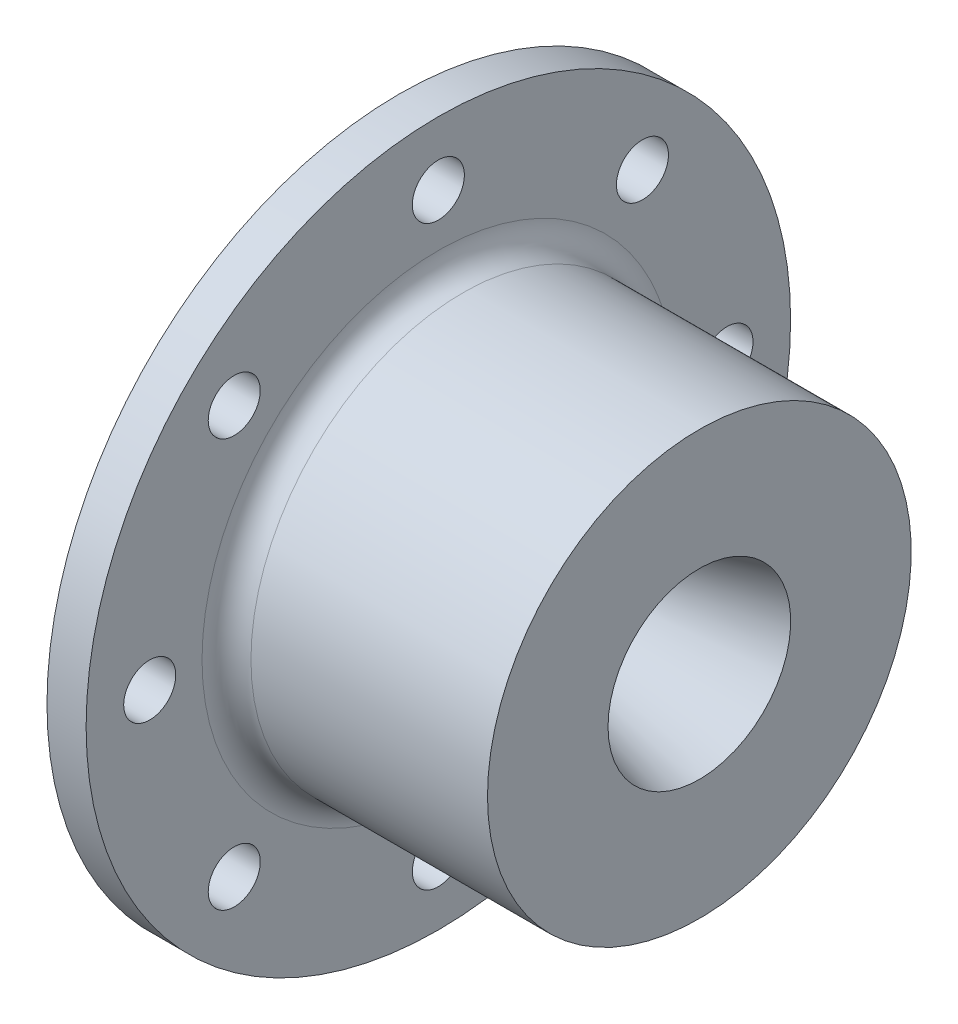
from build123d import *

# Parameters (mm, degrees)
RAO_OUTLET_RADIUS_R     = 2.742884532
F_1_4_CLEARANCE_HOLE1_D = 6.7564
SKETCH5_OUTSIDE_W       = 174.362
SKETCH5_OUTSIDE_H       = 174.362
SKETCH5_OUTSIDE_R       = 45.72
CUT_EXTRUDE1_DEPTH      = 5.08
FILLET1_R               = 3.175
RAO_INLET_RADIUS_R      = 10.770489


with BuildPart() as part:
    # Sketch1 → Nozzle (revolve)
    with BuildSketch(Plane.XY):
        Polygon((15.288121734, 7.180326), (21.511121734, 7.180326), (38.957805968, 11.855150951), (38.957805968, 27.500000118), (5.08, 27.500000118), (5.08, 66.870000118), (0, 66.870000118), (0, 25.4), align=None)
    revolve(axis=Axis((0, 0, 0), (1, 0, 0)))

    # Rao outlet radius
    rao_outlet_radius_edges = [part.edges().sort_by_distance(p)[0] for p in [
        (21.511121734, -7.180326, 0),
    ]]
    fillet(rao_outlet_radius_edges, radius=RAO_OUTLET_RADIUS_R)

    # 1/4 Clearance Hole1 (through all)
    with Locations(Plane.ZY):
        with Locations((37.465, 0), (26.491755557, -26.491755557), (0, -37.465), (-26.491755557, -26.491755557), (-37.465, 0), (-26.491755557, 26.491755557), (0, 37.465), (26.491755557, 26.491755557), (0, 0)):
            Hole(F_1_4_CLEARANCE_HOLE1_D / 2)

    # Sketch5 outside → Cut-Extrude1 (cut)
    with BuildSketch(Plane(origin=(0, 0, 0), x_dir=(0, 0, -1), z_dir=(1, 0, 0))):
        Rectangle(SKETCH5_OUTSIDE_W, SKETCH5_OUTSIDE_H)
        Circle(SKETCH5_OUTSIDE_R, mode=Mode.SUBTRACT)
    extrude(amount=CUT_EXTRUDE1_DEPTH, mode=Mode.SUBTRACT)

    # Fillet1
    fillet1_edges = [part.edges().sort_by_distance(p)[0] for p in [
        (5.08, -27.500000118, 0),
    ]]
    fillet(fillet1_edges, radius=FILLET1_R)

    # Rao Inlet radius
    rao_inlet_radius_edges = [part.edges().sort_by_distance(p)[0] for p in [
        (15.288121734, -7.180326, 0),
    ]]
    fillet(rao_inlet_radius_edges, radius=RAO_INLET_RADIUS_R)


solid = part.part
